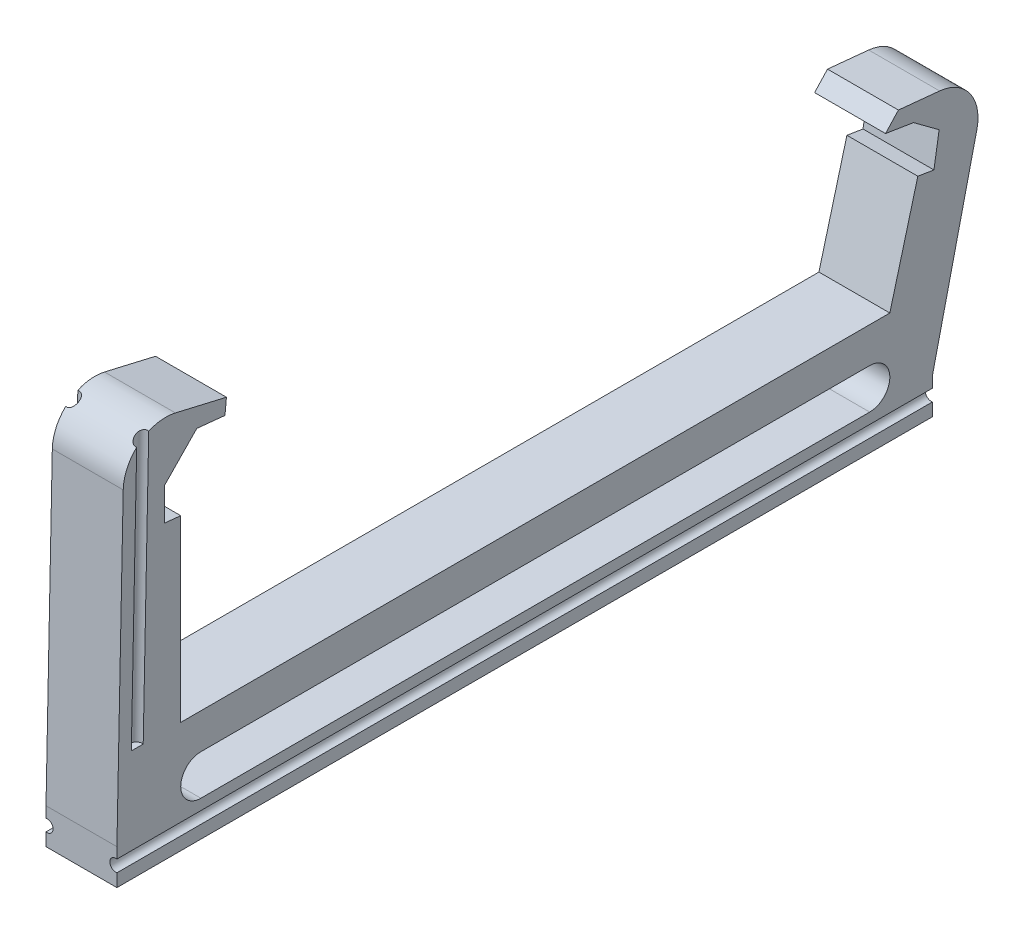
from build123d import *

# Parameters (mm, degrees)
BOSS_EXTRUDE1_DEPTH = 10
CUT_EXTRUDE4_REACH  = 126.4
CUT_EXTRUDE5_DEPTH  = 120.20766697


with BuildPart() as part:
    # Sketch1 → Boss-Extrude1 (new body)
    with BuildSketch(Plane(origin=(0, 0, 0), x_dir=(0, 0, -1), z_dir=(1, 0, 0))):
        with BuildLine():
            Line((0, 0), (100, 0))
            Line((100, 0), (103.946990438, 14.730368851))
            Line((103.946990438, 14.730368851), (106.217403847, 14.362642119))
            Line((106.217403847, 14.362642119), (106.952857311, 18.903468939))
            Line((106.952857311, 18.903468939), (103.341565092, 21.580990302))
            Line((103.341565092, 21.580990302), (99.393020031, 22.220515053))
            Line((99.393020031, 22.220515053), (101.210603817, 24.179837998))
            Line((101.210603817, 24.179837998), (107.020951621, 23.60910455))
            ThreePointArc((107.020951621, 23.60910455), (111.310577018, 21.133985308), (112.278030397, 16.276914661))
            Line((112.278030397, 16.276914661), (106, -10.68))
            Line((106, -10.68), (106, -15.68))
            Line((106, -15.68), (-9, -15.68))
            Line((-9, -15.68), (-9, -10.68))
            Line((-9, -10.68), (-8.111602248, 32.45071604))
            ThreePointArc((-8.111602248, 32.45071604), (-5.794866244, 37.064553263), (-0.751946881, 38.17077383))
            Line((-0.751946881, 38.17077383), (6.44531119, 36.494595175))
            Line((6.44531119, 36.494595175), (6.242876448, 34.365871735))
            Line((6.242876448, 34.365871735), (2.263353613, 34.770096924))
            Line((2.263353613, 34.770096924), (-2.28822563, 30.082429484))
            Line((-2.28822563, 30.082429484), (-2.28822563, 25.482429484))
            Line((-2.28822563, 25.482429484), (0, 25.25))
            Line((0, 25.25), (0, 0))
        make_face()
        with BuildLine():
            Line((2.84, -5), (97.16, -5))
            ThreePointArc((97.16, -5), (100, -7.84), (97.16, -10.68))
            Line((97.16, -10.68), (2.84, -10.68))
            ThreePointArc((2.84, -10.68), (0, -7.84), (2.84, -5))
        make_face(mode=Mode.SUBTRACT)
    extrude(amount=BOSS_EXTRUDE1_DEPTH)

    # Cut-Extrude4: up to this plane
    cut_extrude4_end = Plane(origin=(0, 0, 0), z_dir=(0, 1, 0))
    # Sketch2 → Cut-Extrude4 (cut, up to the surface)
    with BuildSketch(Plane(origin=(0, 38.268671352, -0.788250341), x_dir=(1, 0, 0), z_dir=(0, 0.9997879328481811, -0.020593429320073266)), mode=Mode.PRIVATE) as cut_extrude4_sk1:
        with BuildLine():
            Line((0, -5.291493544), (0, -6.964813597))
            ThreePointArc((0, -6.964813597), (1, -6.12815357), (0, -5.291493544))
        make_face()
    cut_extrude4_tool1 = split(extrude(cut_extrude4_sk1.sketch, amount=-CUT_EXTRUDE4_REACH, mode=Mode.PRIVATE), bisect_by=cut_extrude4_end, keep=Keep.BOTH, mode=Mode.PRIVATE)
    cut_extrude4 = cut_extrude4_tool1.solids().sort_by_distance((0.431182, 38.394871, 5.338604))[0]
    add(cut_extrude4, mode=Mode.SUBTRACT)

    # Mirror1: Cut-Extrude4 across plane
    add(cut_extrude4.mirror(Plane(origin=(5, 0, 0), x_dir=(0, 0, 1), z_dir=(1, 0, 0))), mode=Mode.SUBTRACT)

    # Sketch3 → Cut-Extrude5 (cut, symmetric)
    with BuildSketch(Plane.XY):
        with BuildLine():
            ThreePointArc((0, -13.866660027), (1, -13.03), (0, -12.193339973))
            Line((0, -12.193339973), (0, -13.866660027))
        make_face()
    cut_extrude5 = extrude(amount=CUT_EXTRUDE5_DEPTH, both=True, mode=Mode.SUBTRACT)

    # Mirror2: Cut-Extrude5 across plane
    add(cut_extrude5.mirror(Plane(origin=(5, 0, 0), x_dir=(0, 0, 1), z_dir=(1, 0, 0))), mode=Mode.SUBTRACT)


solid = part.part
